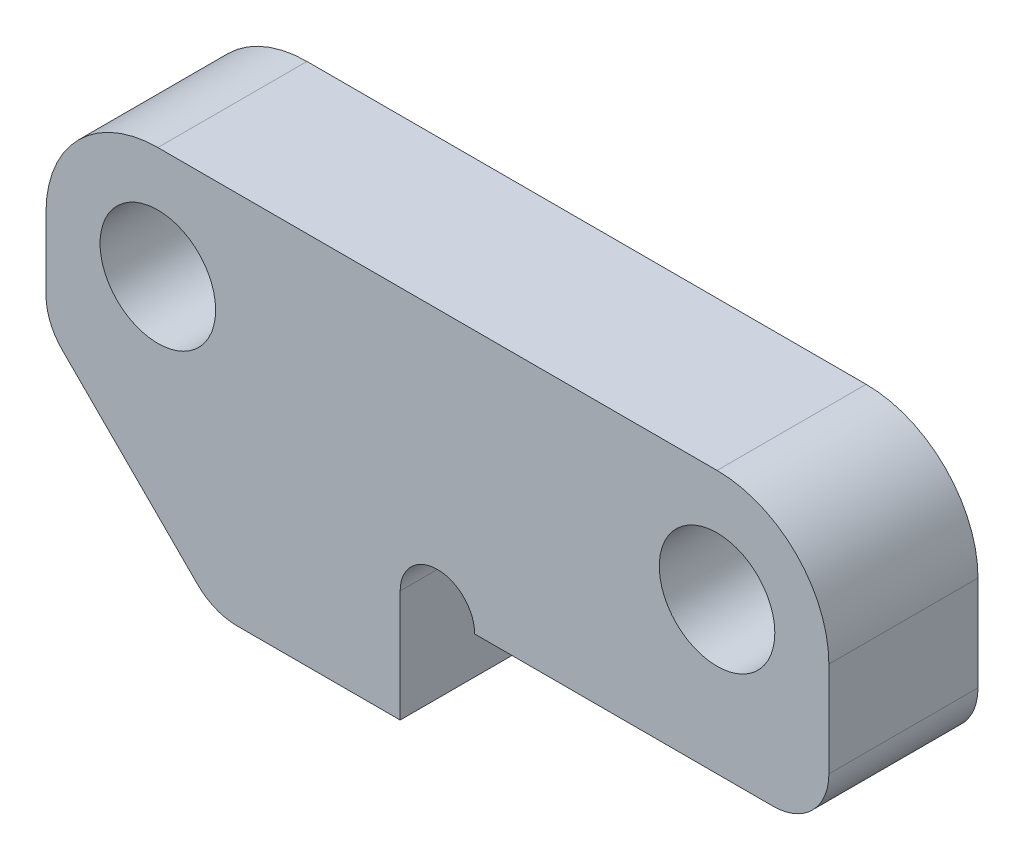
from build123d import *

# Parameters (mm, degrees)
SKETCH_1_R          = 1.55
EXTRUDE_1_DEPTH     = 2
FILLET_1_R          = 3
FILLET_2_R          = 1.5
SKETCH_3_R          = 1
CUT_EXTRUDE_1_DEPTH = 5


with BuildPart() as part:
    # 草图1 → 凸台-拉伸1 (new body, symmetric)
    with BuildSketch(Plane.XY):
        Polygon((-10.5, 0), (10.5, 0), (10.5, -7.05), (-1, -7.05), (-1, -10.05), (-6, -10.05), (-10.5, -5.55), align=None)
        with Locations((-7.5, -3)):
            Circle(SKETCH_1_R, mode=Mode.SUBTRACT)
        with Locations((7.5, -3)):
            Circle(SKETCH_1_R, mode=Mode.SUBTRACT)
    extrude(amount=EXTRUDE_1_DEPTH, both=True)

    # 圆角1
    fillet_1_edges = [part.edges().sort_by_distance(p)[0] for p in [
        (-10.5, 0, 0),
        (10.5, 0, 0),
    ]]
    fillet(fillet_1_edges, radius=FILLET_1_R)

    # 圆角2
    fillet_2_edges = [part.edges().sort_by_distance(p)[0] for p in [
        (10.5, -7.05, 0),
        (-6, -10.05, 0),
        (-10.5, -5.55, 0),
    ]]
    fillet(fillet_2_edges, radius=FILLET_2_R)

    # 草图3 → 切除-拉伸1 (cut, through all)
    with BuildSketch(Plane.XY.offset(2)):
        with Locations((0, -7.05)):
            Circle(SKETCH_3_R)
    extrude(amount=-CUT_EXTRUDE_1_DEPTH, mode=Mode.SUBTRACT)


solid = part.part
